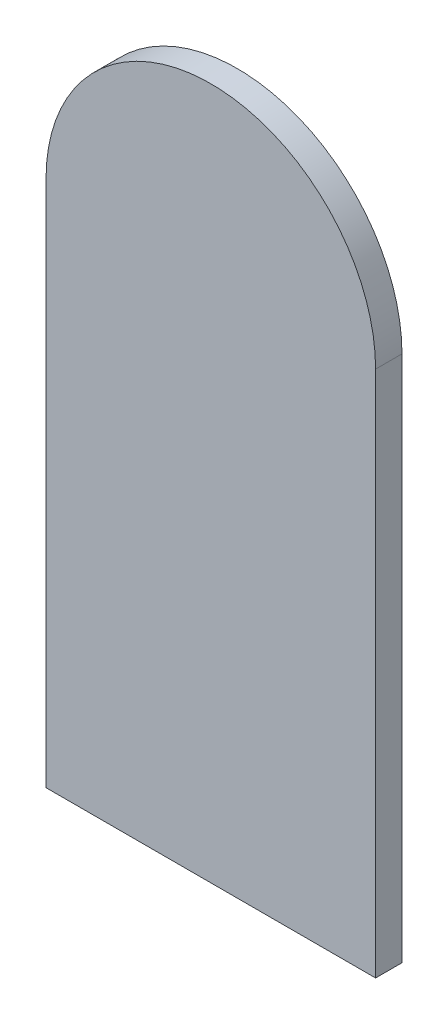
from build123d import *

# Parameters (mm, degrees)
BOSS_EXTRUDE1_DEPTH = 1


with BuildPart() as part:
    # Sketch1 → Boss-Extrude1 (new body)
    with BuildSketch(Plane.XY):
        with BuildLine():
            Line((0, 0), (-12.5, 0))
            Line((-12.5, 0), (-12.5, 20))
            ThreePointArc((-12.5, 20), (-6.25, 26.25), (0, 20))
            Line((0, 20), (0, 0))
        make_face()
    extrude(amount=BOSS_EXTRUDE1_DEPTH)


solid = part.part
